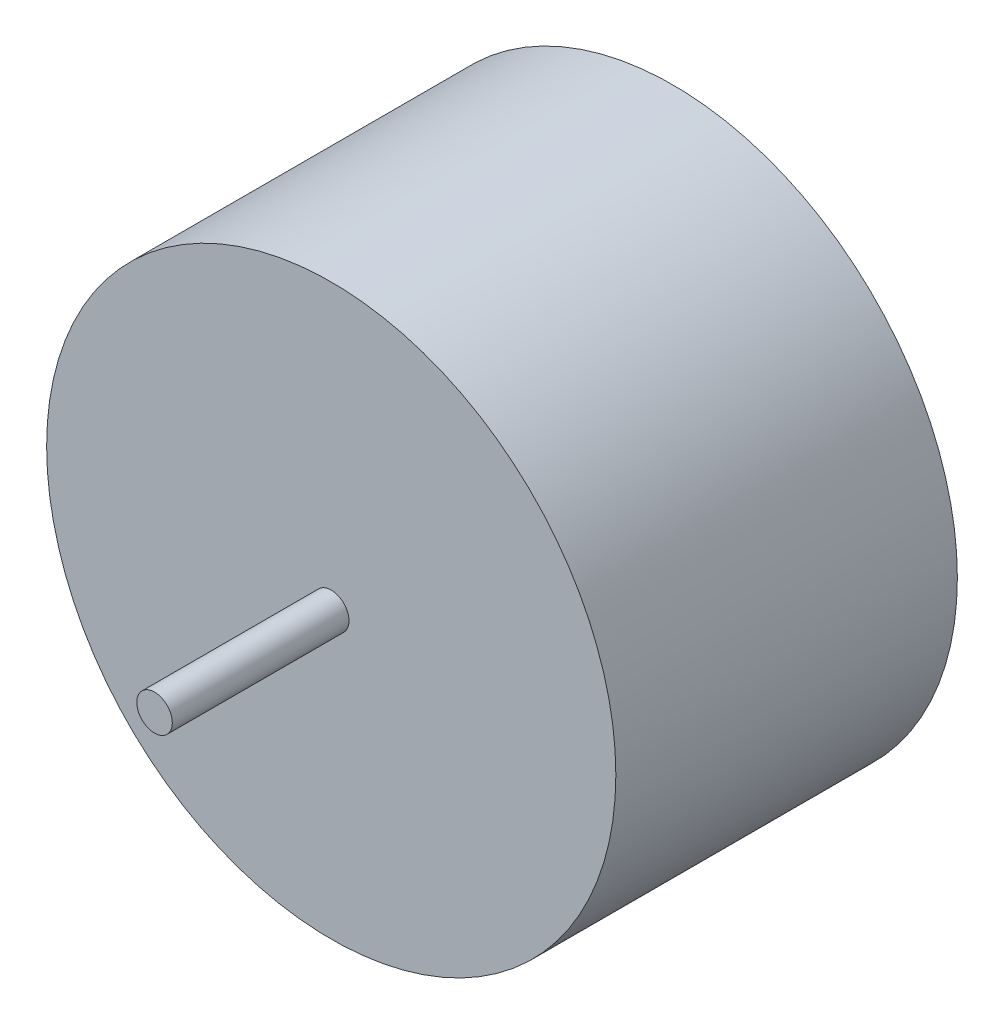
from build123d import *

# Parameters (mm, degrees)
SKETCH2_R           = 15.875
BOSS_EXTRUDE1_DEPTH = 28.9052
CUT_EXTRUDE1_START  = 28.9052
SKETCH3_OUTSIDE_W   = 44.43
SKETCH3_OUTSIDE_H   = 44.43
SKETCH3_OUTSIDE_R   = 0.9906
CUT_EXTRUDE1_DEPTH  = 9.8552


with BuildPart() as part:
    # Sketch2 → Boss-Extrude1 (new body)
    with BuildSketch(Plane.XY):
        Circle(SKETCH2_R)
    extrude(amount=BOSS_EXTRUDE1_DEPTH)

    # Sketch3 outside → Cut-Extrude1 (cut)
    with BuildSketch(Plane.XY.offset(CUT_EXTRUDE1_START)):
        Rectangle(SKETCH3_OUTSIDE_W, SKETCH3_OUTSIDE_H)
        Circle(SKETCH3_OUTSIDE_R, mode=Mode.SUBTRACT)
    extrude(amount=-CUT_EXTRUDE1_DEPTH, mode=Mode.SUBTRACT)


solid = part.part
